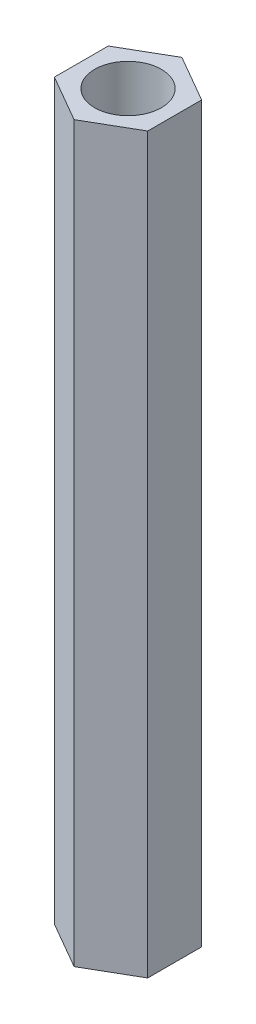
from build123d import *

# Parameters (mm, degrees)
SKETCH_1_R      = 2.5
EXTRUDE_1_DEPTH = 55


with BuildPart() as part:
    # 草图1 → 凸台-拉伸1 (new body)
    with BuildSketch(Plane(origin=(0, 0, 0), x_dir=(1, 0, 0), z_dir=(0, 1, 0))):
        Polygon((0, 4.041451884), (-3.5, 2.020725942), (-3.5, -2.020725942), (0, -4.041451884), (3.5, -2.020725942), (3.5, 2.020725942), align=None)
        Circle(SKETCH_1_R, mode=Mode.SUBTRACT)
    extrude(amount=EXTRUDE_1_DEPTH)


solid = part.part
